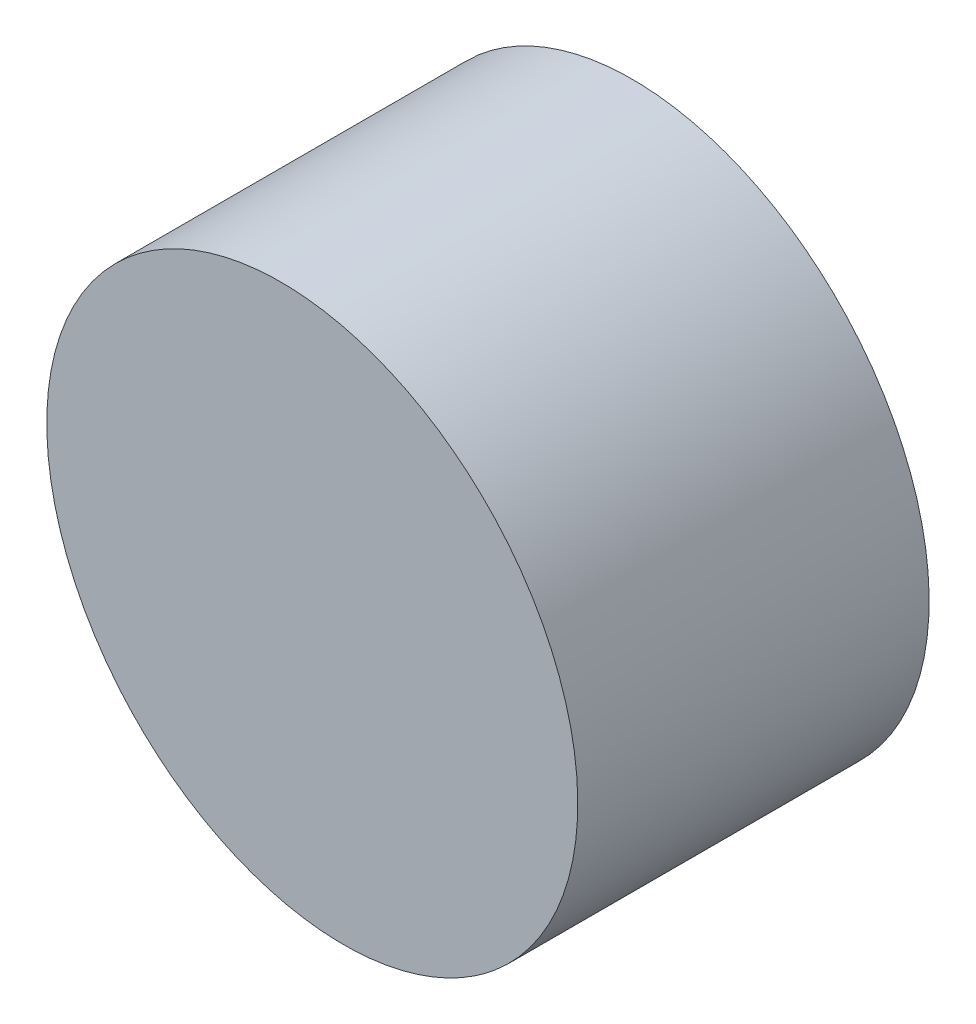
from build123d import *

# Parameters (mm, degrees)
SKETCH_1_RX     = 30.806874859
SKETCH_1_RY     = 27.303357218
EXTRUDE_1_DEPTH = 38.1


with BuildPart() as part:
    # 草图1 → 凸台-拉伸1 (new body)
    with BuildSketch(Plane.XY):
        with Locations(Location((0, 0), (0, 0, -50.162240271))):
            Ellipse(SKETCH_1_RX, SKETCH_1_RY)
    extrude(amount=EXTRUDE_1_DEPTH)


solid = part.part
